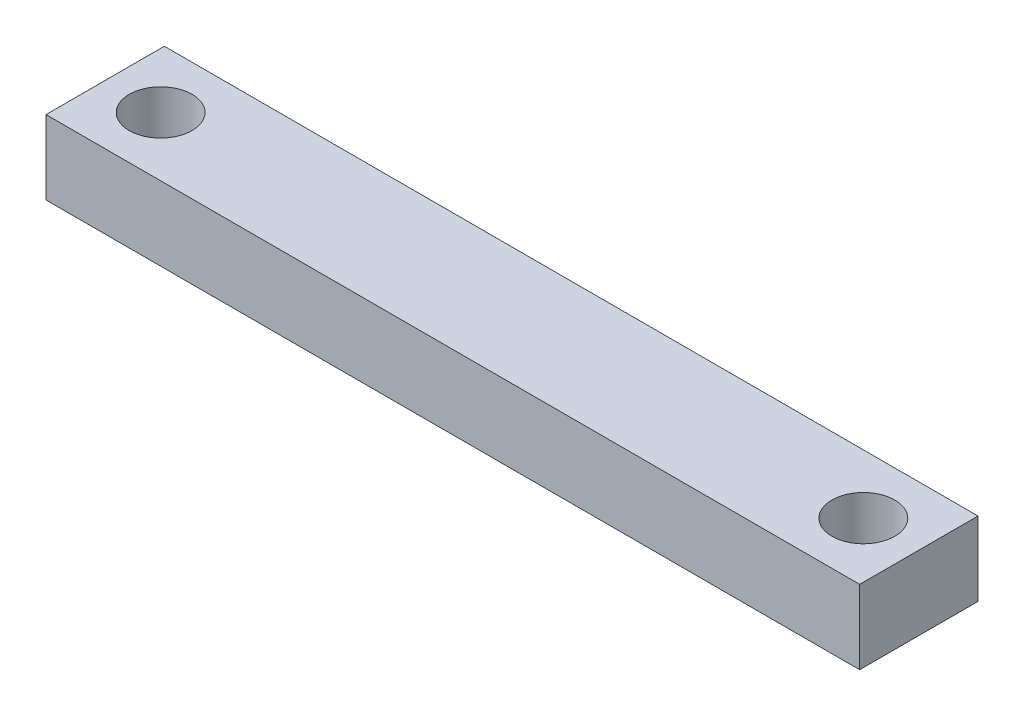
from build123d import *

# Parameters (mm, degrees)
SKETCH_1_W              = 110
SKETCH_1_H              = 16
EXTRUDE_1_DEPTH         = 10
HOLE_WIZARD_M10_1_D     = 8.5
HOLE_WIZARD_M10_1_DEPTH = 24.5
HOLE_WIZARD_M10_1_TIP   = 2.553657631


with BuildPart() as part:
    # 草图1 → 凸台-拉伸1 (new body)
    with BuildSketch(Plane(origin=(0, 0, 0), x_dir=(1, 0, 0), z_dir=(0, 1, 0))):
        Rectangle(SKETCH_1_W, SKETCH_1_H)
    extrude(amount=EXTRUDE_1_DEPTH)

    # M10 螺纹孔1
    with Locations(Plane(origin=(-47.5, 10, 0), x_dir=(0, 0, 1), z_dir=(0, 1, 0))):
        with Locations((0, 0), (0, 95)):
            Hole(HOLE_WIZARD_M10_1_D / 2, depth=HOLE_WIZARD_M10_1_DEPTH)
            with Locations((0, 0, -(HOLE_WIZARD_M10_1_DEPTH + HOLE_WIZARD_M10_1_TIP / 2))):  # 118° drill point
                Cone(0, HOLE_WIZARD_M10_1_D / 2, HOLE_WIZARD_M10_1_TIP, mode=Mode.SUBTRACT)


solid = part.part
